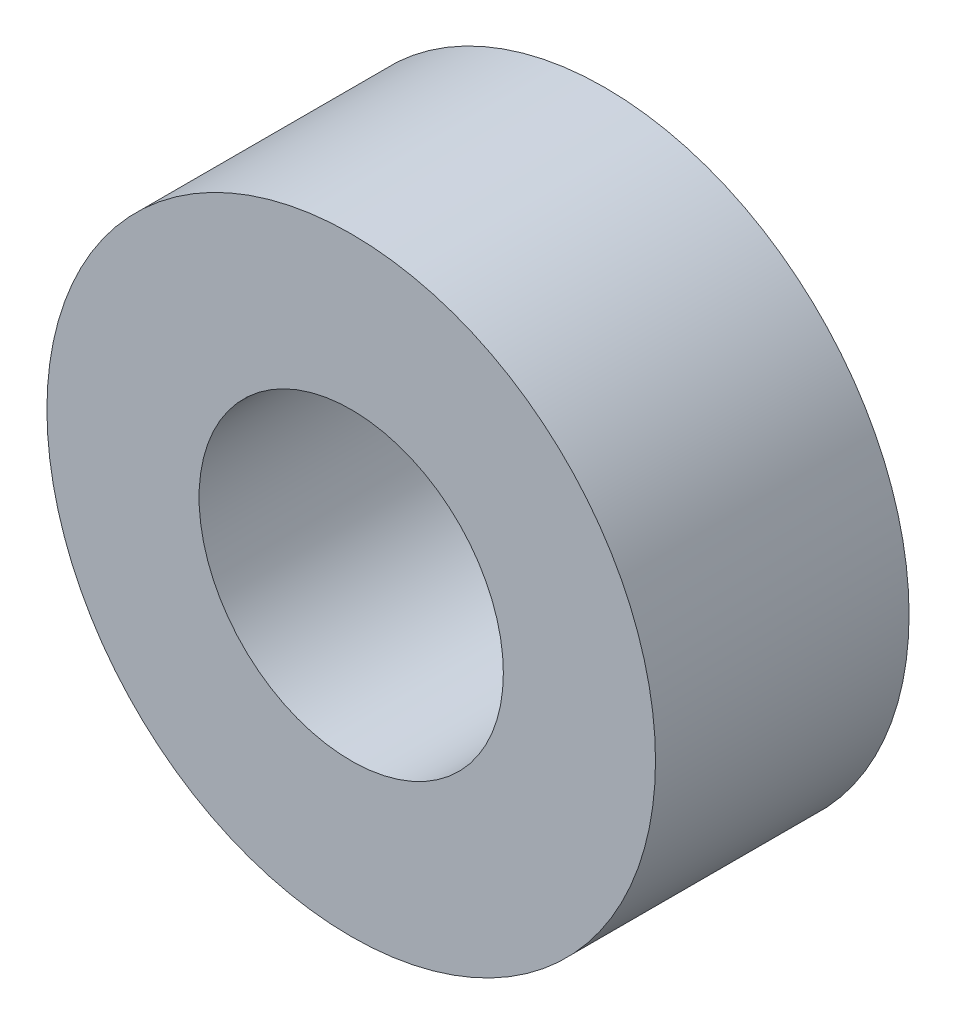
from build123d import *

# Parameters (mm, degrees)
SKETCH1_R      = 3
SKETCH1_R_2    = 1.5
EXTRUDE1_DEPTH = 2.5


with BuildPart() as part:
    # Sketch1 → Extrude1 (new body)
    with BuildSketch(Plane.XY):
        Circle(SKETCH1_R)
        Circle(SKETCH1_R_2, mode=Mode.SUBTRACT)
    extrude(amount=EXTRUDE1_DEPTH)


solid = part.part
